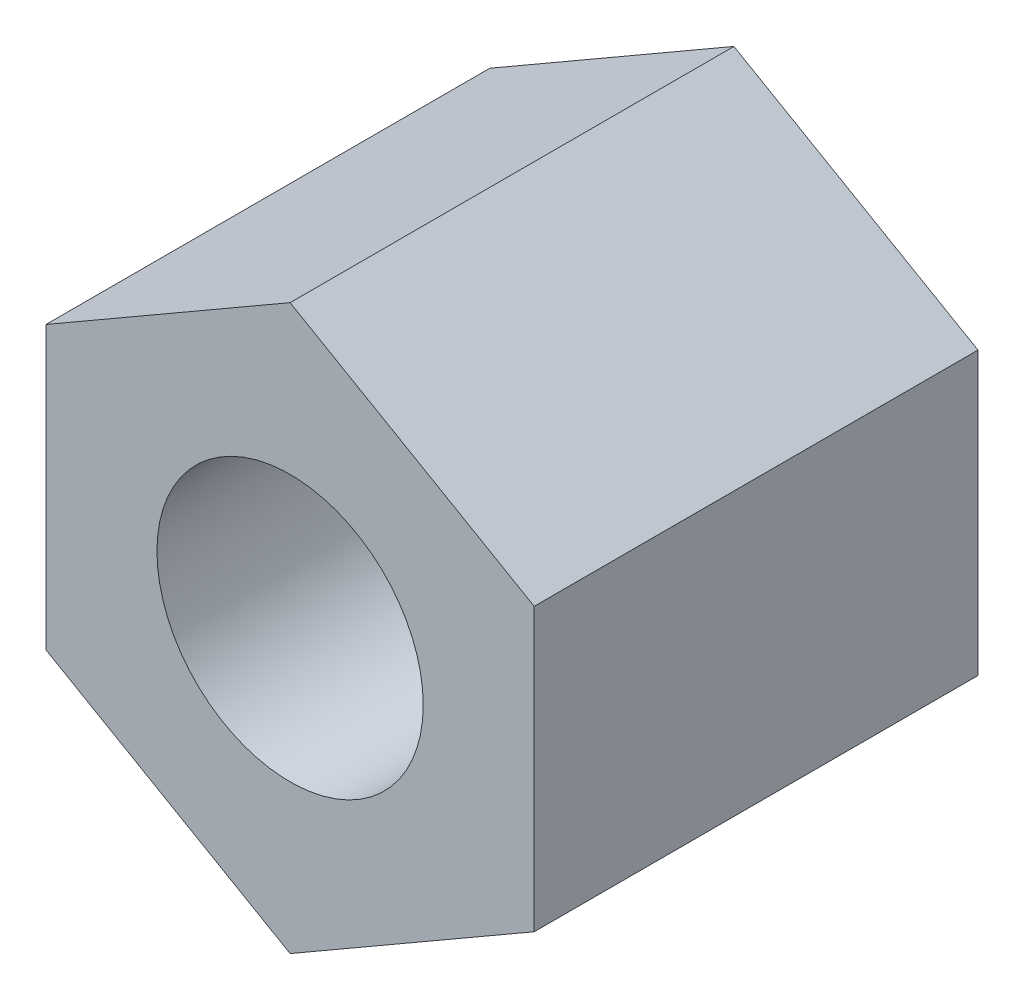
from build123d import *

# Parameters (mm, degrees)
SKETCH_1_R      = 1.5
EXTRUDE_1_DEPTH = 5


with BuildPart() as part:
    # Эскиз1 → Бобышка-Вытянуть1 (new body)
    with BuildSketch(Plane.XY):
        Polygon((0, -3.175426481), (2.75, -1.58771324), (2.75, 1.58771324), (0, 3.175426481), (-2.75, 1.58771324), (-2.75, -1.58771324), align=None)
        Circle(SKETCH_1_R, mode=Mode.SUBTRACT)
    extrude(amount=EXTRUDE_1_DEPTH)


solid = part.part
